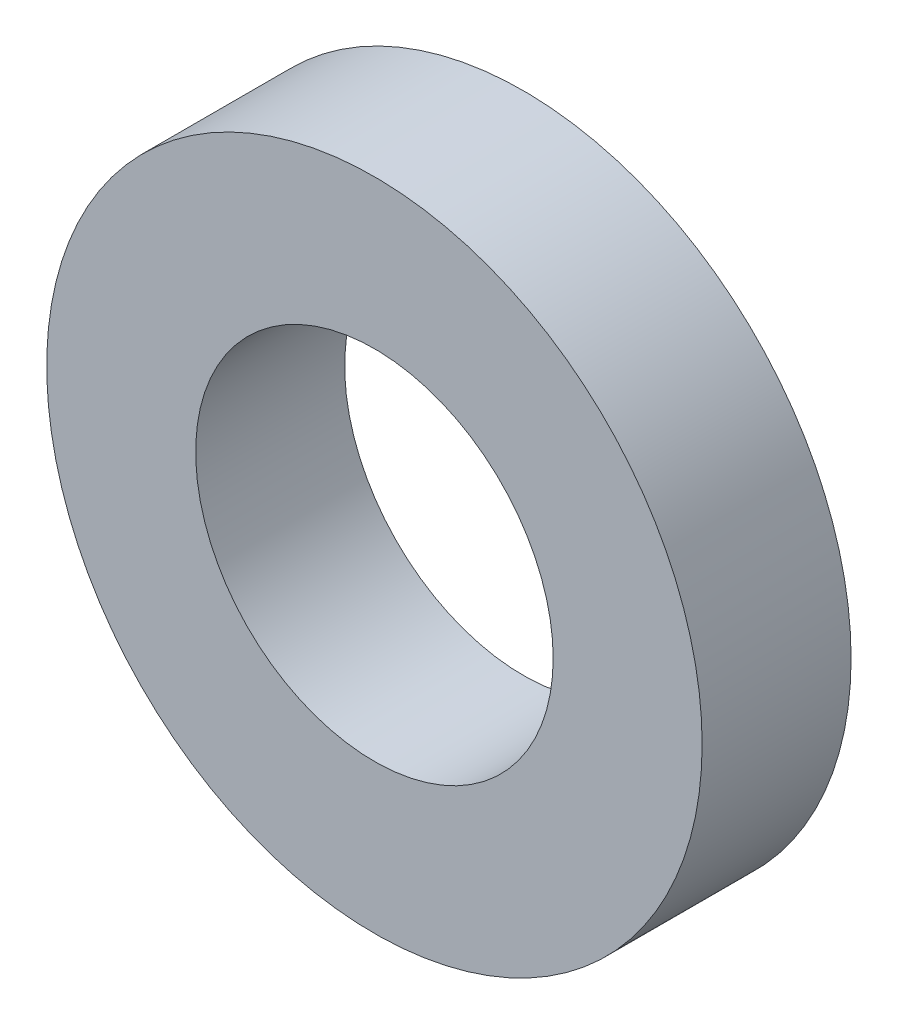
from build123d import *

# Parameters (mm, degrees)
SKETCH_1_R      = 11
SKETCH_1_R_2    = 6
EXTRUDE_1_DEPTH = 5


with BuildPart() as part:
    # Эскиз1 → Бобышка-Вытянуть1 (new body)
    with BuildSketch(Plane.XY):
        Circle(SKETCH_1_R)
        Circle(SKETCH_1_R_2, mode=Mode.SUBTRACT)
    extrude(amount=EXTRUDE_1_DEPTH)


solid = part.part
